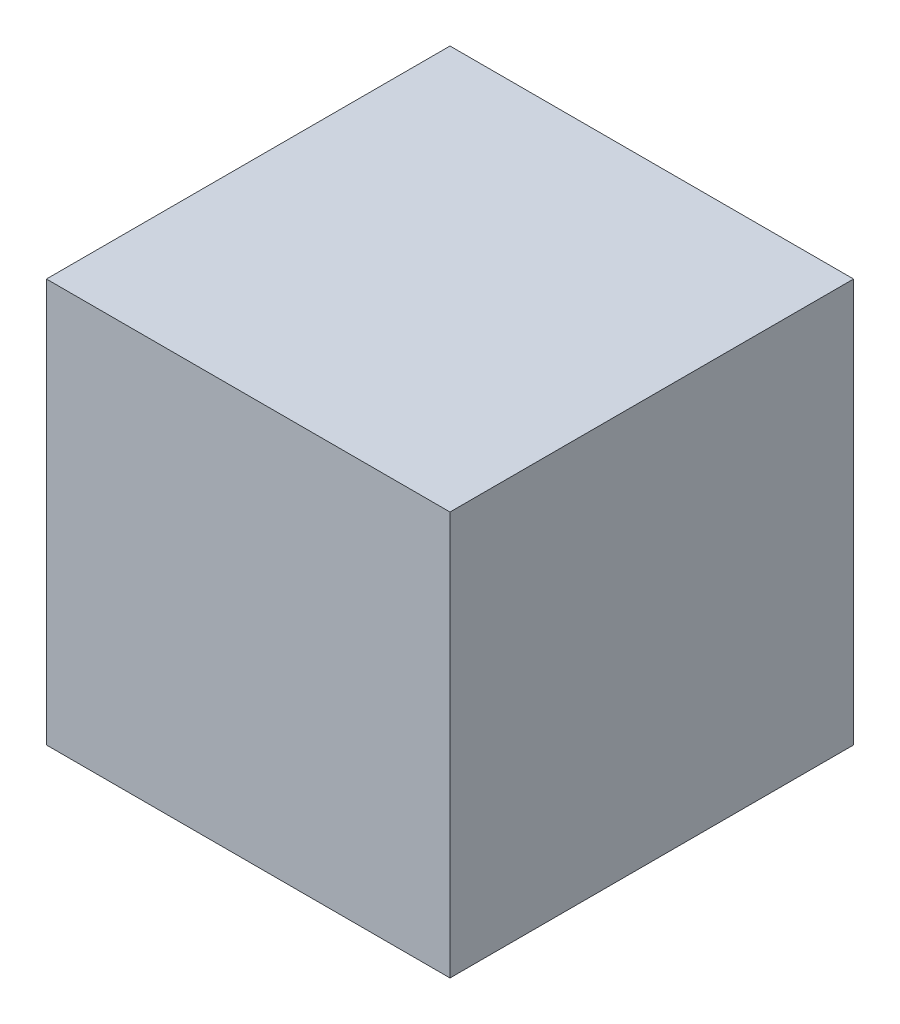
from build123d import *

# Parameters (mm, degrees)
SKETCH_1_W      = 10
SKETCH_1_H      = 10
EXTRUDE_1_DEPTH = 10


with BuildPart() as part:
    # 草图1 → 凸台-拉伸1 (new body)
    with BuildSketch(Plane.XY):
        with Locations((5, 5)):
            Rectangle(SKETCH_1_W, SKETCH_1_H)
    extrude(amount=EXTRUDE_1_DEPTH)


solid = part.part
